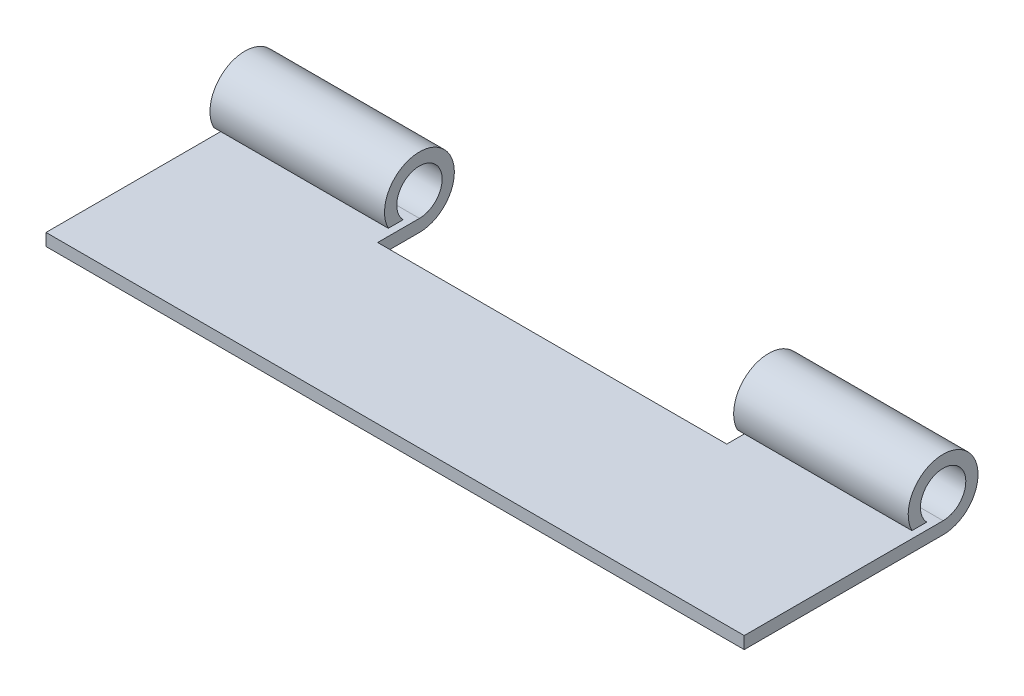
from build123d import *

# Parameters (mm, degrees)
SKETCH1_W           = 50.8
SKETCH1_H           = 15.875
BOSS_EXTRUDE1_DEPTH = 0.889
SKETCH3_W           = 7.62
SKETCH3_H           = 12.7
CUT_EXTRUDE1_DEPTH  = 51.8
BOSS_EXTRUDE6_DEPTH = 12.7
BOSS_EXTRUDE7_START = -25.4
BOSS_EXTRUDE7_DEPTH = 12.7


with BuildPart() as part:
    # Sketch1 → Boss-Extrude1 (new body)
    with BuildSketch(Plane(origin=(0, 0, 0), x_dir=(1, 0, 0), z_dir=(0, 1, 0))):
        with Locations((25.4, 7.9375)):
            Rectangle(SKETCH1_W, SKETCH1_H)
    extrude(amount=BOSS_EXTRUDE1_DEPTH)

    # Sketch3 → Cut-Extrude1 (cut, through all)
    with BuildSketch(Plane(origin=(50.8, 0, 0), x_dir=(0, 0, -1), z_dir=(1, 0, 0))):
        with Locations((0.635, -0.009678267)):
            Rectangle(SKETCH3_W, SKETCH3_H)
    extrude(amount=-CUT_EXTRUDE1_DEPTH, mode=Mode.SUBTRACT)

    # Sketch4 → Boss-Extrude6 (add)
    with BuildSketch(Plane(origin=(38.1, 0, 0), x_dir=(0, 0, -1), z_dir=(1, 0, 0))):
        with BuildLine():
            Line((15.875, 0.889), (18.915054155, 0.889))
            ThreePointArc((18.915054155, 0.889), (19.562629634, 4.058699114), (17.723688552, 1.397))
            Line((17.723688552, 1.397), (16.646761626, 1.397))
            ThreePointArc((16.646761626, 1.397), (20.247041392, 4.702732068), (18.915054155, 0))
            Line((18.915054155, 0), (15.875, 0))
            Line((15.875, 0), (15.875, 0.889))
        make_face()
    extrude(amount=BOSS_EXTRUDE6_DEPTH)

    # Sketch4_4 → Boss-Extrude7 (add)
    with BuildSketch(Plane(origin=(38.1, 0, 0), x_dir=(0, 0, -1), z_dir=(1, 0, 0)).offset(BOSS_EXTRUDE7_START)):
        with BuildLine():
            Line((15.875, 0.889), (18.915054155, 0.889))
            ThreePointArc((18.915054155, 0.889), (19.562629634, 4.058699114), (17.723688552, 1.397))
            Line((17.723688552, 1.397), (16.646761626, 1.397))
            ThreePointArc((16.646761626, 1.397), (20.247041392, 4.702732068), (18.915054155, 0))
            Line((18.915054155, 0), (15.875, 0))
            Line((15.875, 0), (15.875, 0.889))
        make_face()
    extrude(amount=-BOSS_EXTRUDE7_DEPTH)


solid = part.part
